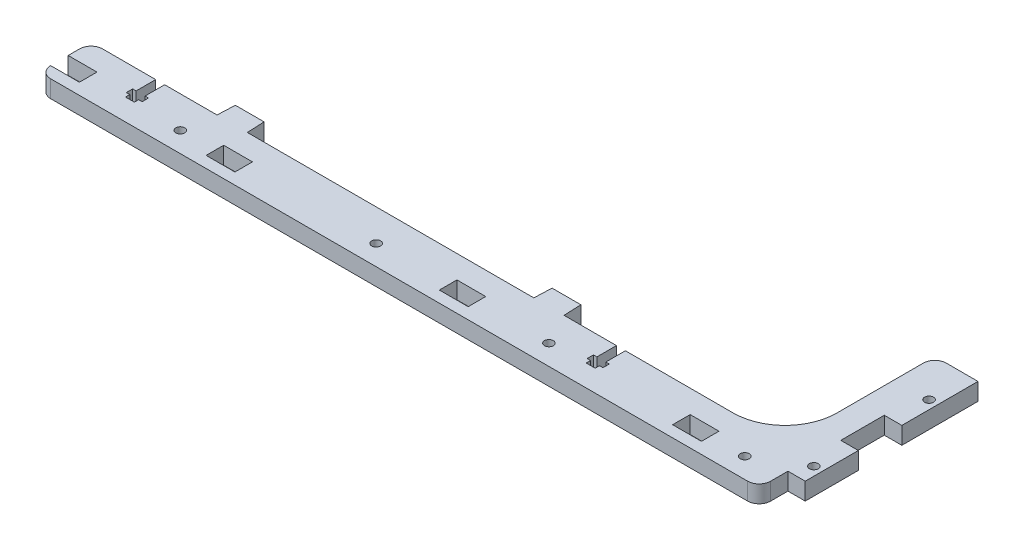
from build123d import *

# Parameters (mm, degrees)
SKETCH_1_R      = 1.55
SKETCH_1_W      = 10
SKETCH_1_H      = 6.1
EXTRUDE_1_DEPTH = 6


with BuildPart() as part:
    # Эскиз1 → Бобышка-Вытянуть1 (new body)
    with BuildSketch(Plane(origin=(0, 0, 0), x_dir=(1, 0, 0), z_dir=(0, 1, 0))):
        with BuildLine():
            Line((33.891038961, -17.86953047), (32.691038961, -17.86953047))
            Line((32.691038961, -17.86953047), (32.691038961, -20.06953047))
            Line((32.691038961, -20.06953047), (33.891038961, -20.06953047))
            Line((33.891038961, -20.06953047), (33.891038961, -21.56953047))
            Line((33.891038961, -21.56953047), (36.991038961, -21.56953047))
            Line((36.991038961, -21.56953047), (36.991038961, -20.06953047))
            Line((36.991038961, -20.06953047), (38.191038961, -20.06953047))
            Line((38.191038961, -20.06953047), (38.191038961, -17.86953047))
            Line((38.191038961, -17.86953047), (36.991038961, -17.86953047))
            Line((36.991038961, -17.86953047), (36.991038961, -11.06953047))
            Line((36.991038961, -11.06953047), (74.441038961, -11.06953047))
            ThreePointArc((74.441038961, -11.06953047), (87.168961022, -5.797452531), (92.441038961, 6.93046953))
            Line((92.441038961, 6.93046953), (92.441038961, 36.93046953))
            ThreePointArc((92.441038961, 36.93046953), (93.612611836, 39.758896655), (96.441038961, 40.93046953))
            Line((96.441038961, 40.93046953), (107.441038961, 40.93046953))
            Line((107.441038961, 40.93046953), (107.441038961, 14.48046953))
            Line((107.441038961, 14.48046953), (101.341038961, 14.48046953))
            Line((101.341038961, 14.48046953), (101.341038961, -0.61953047))
            Line((101.341038961, -0.61953047), (107.441038961, -0.61953047))
            Line((107.441038961, -0.61953047), (107.441038961, -19.06953047))
            Line((107.441038961, -19.06953047), (101.441038961, -19.06953047))
            Line((101.441038961, -19.06953047), (101.441038961, -25.06953047))
            ThreePointArc((101.441038961, -25.06953047), (100.269466086, -27.897957594), (97.441038961, -29.06953047))
            Line((97.441038961, -29.06953047), (-144.559273551, -29.06953047))
            ThreePointArc((-144.559273551, -29.06953047), (-147.369967416, -27.915580364), (-148.558961039, -25.11953047))
            Line((-148.558961039, -25.11953047), (-138.558961039, -25.11953047))
            Line((-138.558961039, -25.11953047), (-138.558961039, -19.01953047))
            Line((-138.558961039, -19.01953047), (-148.558961039, -19.01953047))
            Line((-148.558961039, -19.01953047), (-148.558961039, -15.06953047))
            ThreePointArc((-148.558961039, -15.06953047), (-147.387388164, -12.241103345), (-144.558961039, -11.06953047))
            Line((-144.558961039, -11.06953047), (-126.108961039, -11.06953047))
            Line((-126.108961039, -11.06953047), (-126.108961039, -17.86953047))
            Line((-126.108961039, -17.86953047), (-127.308961039, -17.86953047))
            Line((-127.308961039, -17.86953047), (-127.308961039, -20.06953047))
            Line((-127.308961039, -20.06953047), (-126.108961039, -20.06953047))
            Line((-126.108961039, -20.06953047), (-126.108961039, -21.56953047))
            Line((-126.108961039, -21.56953047), (-123.008961039, -21.56953047))
            Line((-123.008961039, -21.56953047), (-123.008961039, -20.06953047))
            Line((-123.008961039, -20.06953047), (-121.808961039, -20.06953047))
            Line((-121.808961039, -20.06953047), (-121.808961039, -17.86953047))
            Line((-121.808961039, -17.86953047), (-123.008961039, -17.86953047))
            Line((-123.008961039, -17.86953047), (-123.008961039, -11.06953047))
            Line((-123.008961039, -11.06953047), (-104.808961039, -11.06953047))
            Line((-104.808961039, -11.06953047), (-104.558961039, -4.96953047))
            Line((-104.558961039, -4.96953047), (-94.558961039, -4.96953047))
            Line((-94.558961039, -4.96953047), (-94.308961039, -11.06953047))
            Line((-94.308961039, -11.06953047), (5.191038961, -11.06953047))
            Line((5.191038961, -11.06953047), (5.441038961, -4.96953047))
            Line((5.441038961, -4.96953047), (15.441038961, -4.96953047))
            Line((15.441038961, -4.96953047), (15.691038961, -11.06953047))
            Line((15.691038961, -11.06953047), (33.891038961, -11.06953047))
            Line((33.891038961, -11.06953047), (33.891038961, -17.86953047))
        make_face()
        with Locations((104.441038961, 26.93046953)):
            Circle(SKETCH_1_R, mode=Mode.SUBTRACT)
        with Locations((104.441038961, -13.06953047)):
            Circle(SKETCH_1_R, mode=Mode.SUBTRACT)
        with Locations((-106.558961039, -22.06953047)):
            Circle(SKETCH_1_R, mode=Mode.SUBTRACT)
        with Locations((-38.558961039, -22.06953047)):
            Circle(SKETCH_1_R, mode=Mode.SUBTRACT)
        with Locations((21.441038961, -22.06953047)):
            Circle(SKETCH_1_R, mode=Mode.SUBTRACT)
        with Locations((89.441038961, -22.06953047)):
            Circle(SKETCH_1_R, mode=Mode.SUBTRACT)
        with Locations((-89.558961039, -22.06953047)):
            Rectangle(SKETCH_1_W, SKETCH_1_H, mode=Mode.SUBTRACT)
        with Locations((72.441038961, -22.06953047)):
            Rectangle(SKETCH_1_W, SKETCH_1_H, mode=Mode.SUBTRACT)
        with Locations((-8.558961039, -22.06953047)):
            Rectangle(SKETCH_1_W, SKETCH_1_H, mode=Mode.SUBTRACT)
    extrude(amount=EXTRUDE_1_DEPTH)


solid = part.part
